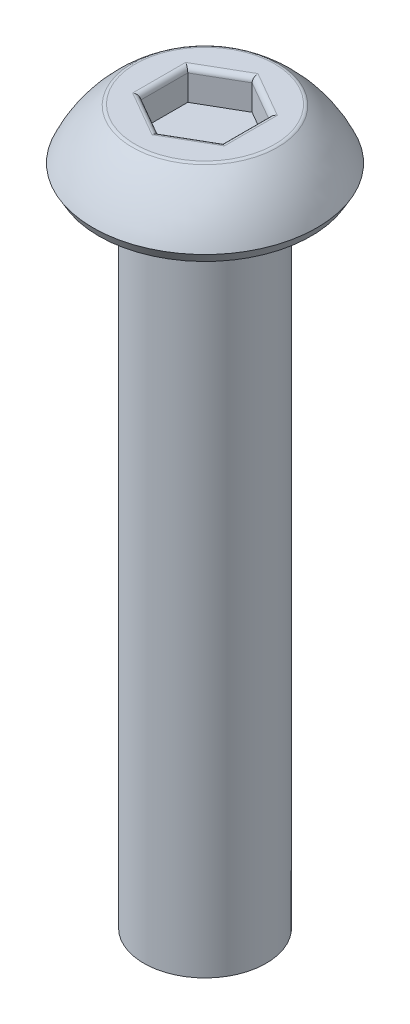
from build123d import *

# Parameters (mm, degrees)
CUT_EXTRUDE1_DEPTH = 0.75
FILLET1_R          = 0.125


with BuildPart() as part:
    # Sketch1 → Revolve1 (revolve)
    with BuildSketch(Plane(origin=(0, 0, 0), x_dir=(0, 0, -1), z_dir=(1, 0, 0))):
        with BuildLine():
            Line((0, 1.5), (-1.75, 1.5))
            ThreePointArc((-1.75, 1.5), (-2.334912942, 0.942930354), (-2.75, 0.25))
            Line((-2.75, 0.25), (-2.605662433, 0))
            Line((-2.605662433, 0), (-1.5, 0))
            Line((-1.5, 0), (-1.5, -16))
            Line((-1.5, -16), (0, -16))
            Line((0, -16), (0, 1.5))
        make_face()
    revolve(axis=Axis((0, -16, 0), (0, 1, 0)))

    # Sketch2 → Cut-Extrude1 (cut)
    with BuildSketch(Plane(origin=(0, 1.5, 0), x_dir=(1, 0, 0), z_dir=(0, 1, 0))):
        Polygon((0, 1.154700538), (-1, 0.577350269), (-1, -0.577350269), (0, -1.154700538), (1, -0.577350269), (1, 0.577350269), align=None)
    extrude(amount=-CUT_EXTRUDE1_DEPTH, mode=Mode.SUBTRACT)

    # Fillet1
    fillet1_edges = [part.edges().sort_by_distance(p)[0] for p in [
        (0.5, 1.5, -0.866025404),
        (-0.5, 1.5, -0.866025404),
        (-1, 1.5, 0),
        (-0.5, 1.5, 0.866025404),
        (0.5, 1.5, 0.866025404),
        (1, 1.5, 0),
        (0, 1.5, -1.75),
    ]]
    fillet(fillet1_edges, radius=FILLET1_R)


solid = part.part
